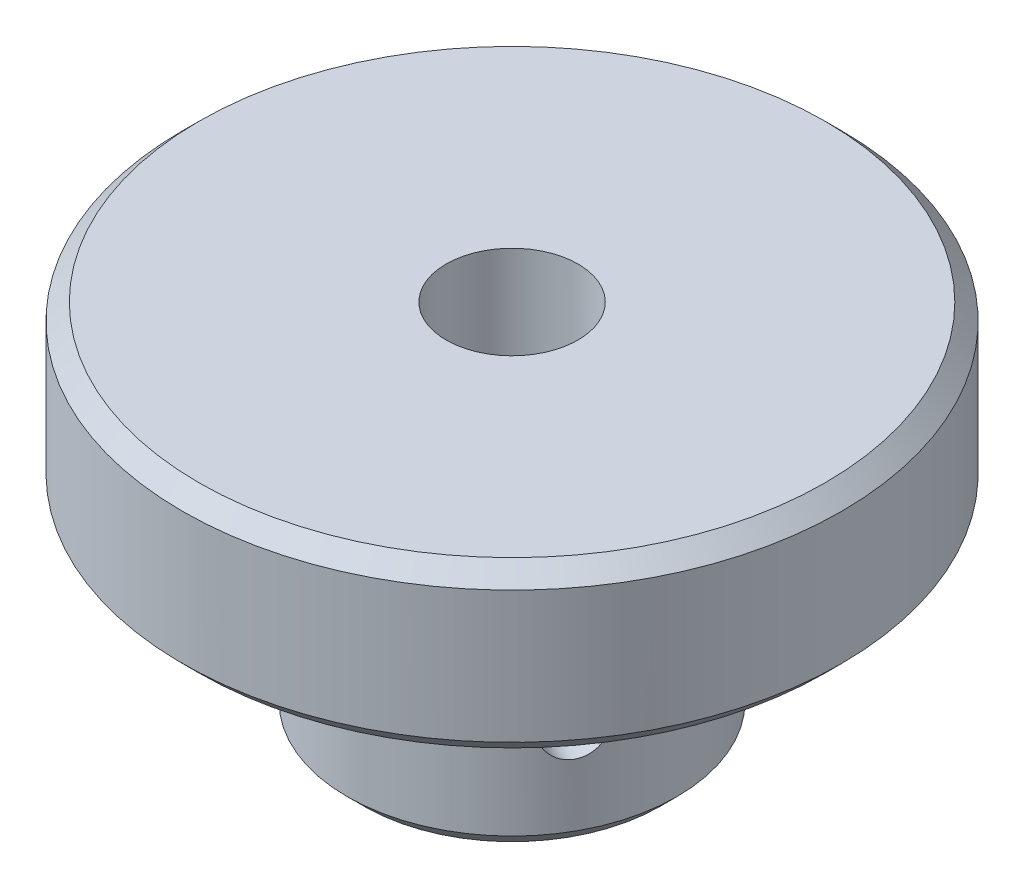
from build123d import *

# Parameters (mm, degrees)
SKETCH2_R                  = 4
CUT_EXTRUDE1_DEPTH         = 36.832945734
CHAMFER1_SIZE              = 1
M4X0_7_TAPPED_HOLE1_REACH  = 41.314
M4X0_7_TAPPED_HOLE1_BORE_R = 1.65
CIRPATTERN3_COUNT          = 2
CIRPATTERN3_ANGLE          = 120


with BuildPart() as part:
    # Sketch1 → Revolve1 (revolve)
    with BuildSketch(Plane.XY):
        Polygon((0, 10), (20, 10), (20, 0), (10, 0), (10, -12), (0, -12), align=None)
    revolve(axis=Axis((0, -12, 0), (0, 1, 0)))

    # Sketch2 → Cut-Extrude1 (cut, through all)
    with BuildSketch(Plane(origin=(0, 10, 0), x_dir=(1, 0, 0), z_dir=(0, 1, 0))):
        with Locations(Location((0, 0, 0), (0, 0, 180))):
            Circle(SKETCH2_R)
    extrude(amount=-CUT_EXTRUDE1_DEPTH, mode=Mode.SUBTRACT)

    # Chamfer1
    chamfer1_edges = [part.edges().sort_by_distance(p)[0] for p in [
        (-10, -12, 0),
        (-20, 0, 0),
        (-20, 10, 0),
    ]]
    chamfer(chamfer1_edges, length=CHAMFER1_SIZE)

    # M4x0.7 Tapped Hole1 bore (on position points) → M4x0.7 Tapped Hole1 (cut, up to next)
    with BuildSketch(Plane(origin=(-0.085304599, -5.563796066, -9.99963615), x_dir=(-0.999963614965, 0, 0.008530459937), z_dir=(-0.008530459937, 0, -0.999963614965)), mode=Mode.PRIVATE) as m4x0_7_tapped_hole1_sk1:
        Circle(M4X0_7_TAPPED_HOLE1_BORE_R)
    m4x0_7_tapped_hole1_tool1 = extrude(m4x0_7_tapped_hole1_sk1.sketch, amount=-M4X0_7_TAPPED_HOLE1_REACH, mode=Mode.PRIVATE) & part.part
    m4x0_7_tapped_hole1 = m4x0_7_tapped_hole1_tool1.solids().sort_by_distance((-0.085305, -5.563796, -9.999636))[0]
    add(m4x0_7_tapped_hole1, mode=Mode.SUBTRACT)

    # CirPattern3: M4x0.7 Tapped Hole1 ×2 about axis
    cirpattern3_axis = Axis((0, -12, 0), (0, -1, 0))
    for i in range(1, CIRPATTERN3_COUNT):
        add(m4x0_7_tapped_hole1.rotate(cirpattern3_axis, i * CIRPATTERN3_ANGLE / (CIRPATTERN3_COUNT - 1)), mode=Mode.SUBTRACT)


solid = part.part
